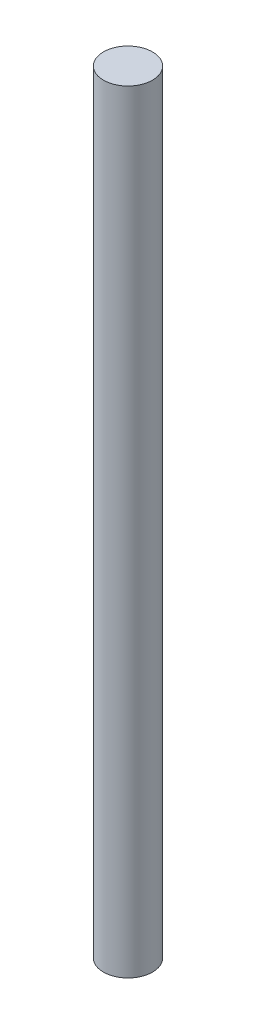
from build123d import *

# Parameters (mm, degrees)
SKETCH1_R                       = 6.35
BOSS_EXTRUDE1_DEPTH             = 200.025
F_32_0_116_DIAMETER_HOLE2_D     = 2.9464
F_32_0_116_DIAMETER_HOLE2_DEPTH = 3.6576
F_32_0_116_DIAMETER_HOLE2_TIP   = 0.885187864


with BuildPart() as part:
    # Sketch1 → Boss-Extrude1 (new body)
    with BuildSketch(Plane(origin=(0, 0, 0), x_dir=(1, 0, 0), z_dir=(0, 1, 0))):
        Circle(SKETCH1_R)
    extrude(amount=BOSS_EXTRUDE1_DEPTH)

    # #32 (0.116) Diameter Hole2
    with Locations(Plane(origin=(0, 0, 0), x_dir=(-1, 0, 0), z_dir=(0, -1, 0))):
        with Locations((0, 0)):
            Hole(F_32_0_116_DIAMETER_HOLE2_D / 2, depth=F_32_0_116_DIAMETER_HOLE2_DEPTH)
            with Locations((0, 0, -(F_32_0_116_DIAMETER_HOLE2_DEPTH + F_32_0_116_DIAMETER_HOLE2_TIP / 2))):  # 118° drill point
                Cone(0, F_32_0_116_DIAMETER_HOLE2_D / 2, F_32_0_116_DIAMETER_HOLE2_TIP, mode=Mode.SUBTRACT)


solid = part.part
